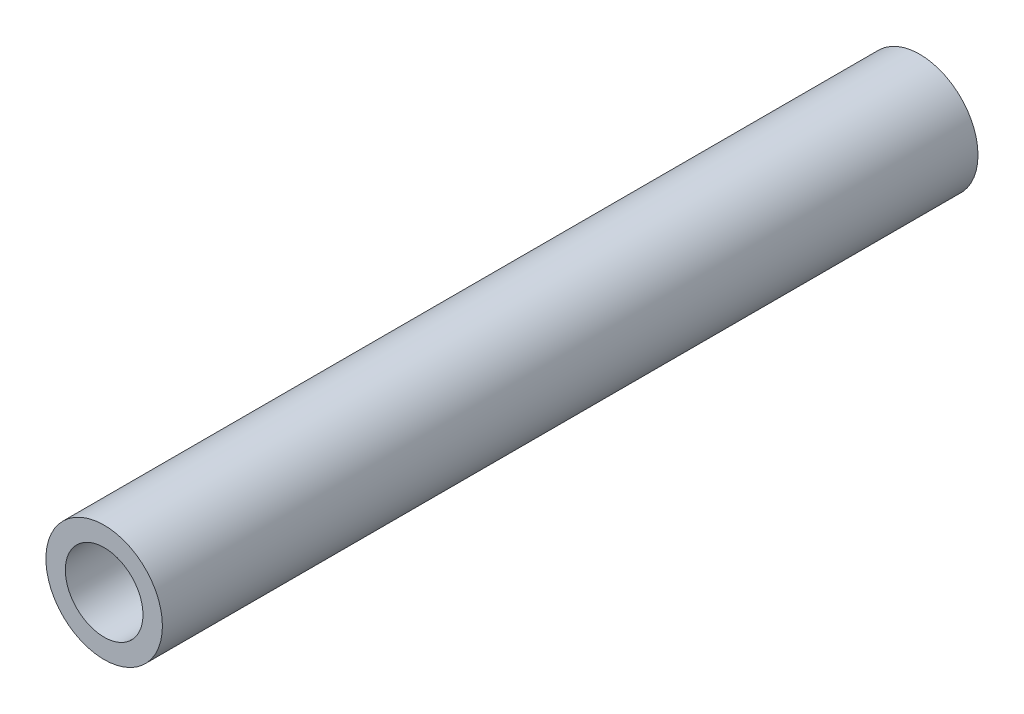
from build123d import *

# Parameters (mm, degrees)
CROQUIS1_R              = 1.5
CROQUIS1_R_2            = 1
SALIENTE_EXTRUIR1_DEPTH = 21


with BuildPart() as part:
    # Croquis1 → Saliente-Extruir1 (new body)
    with BuildSketch(Plane.XY):
        Circle(CROQUIS1_R)
        Circle(CROQUIS1_R_2, mode=Mode.SUBTRACT)
    extrude(amount=SALIENTE_EXTRUIR1_DEPTH)


solid = part.part
